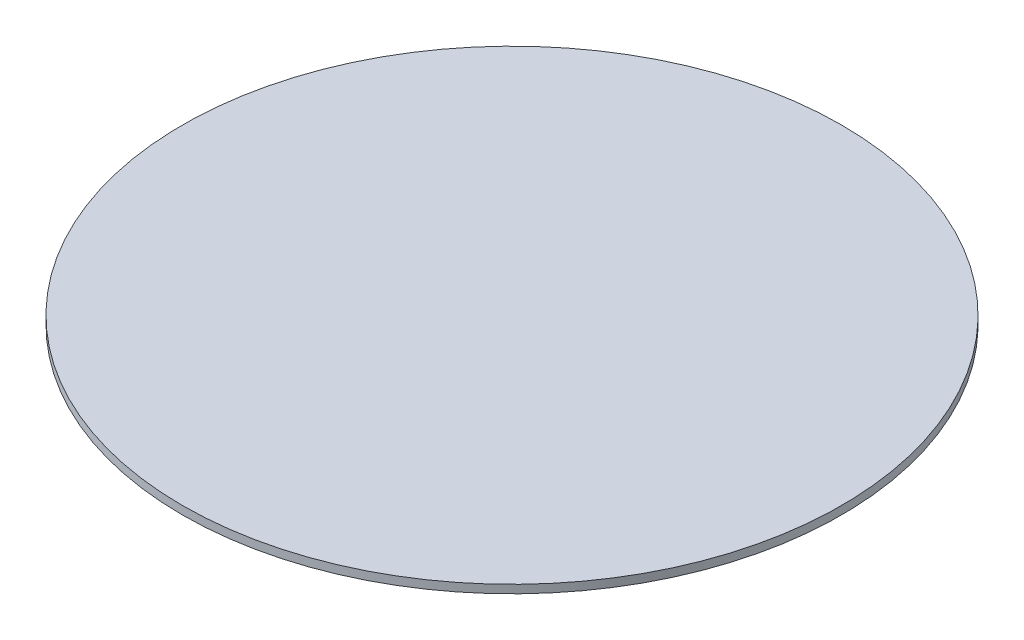
from build123d import *

# Parameters (mm, degrees)
SKETCH1_R           = 60
BOSS_EXTRUDE1_DEPTH = 1.5


with BuildPart() as part:
    # Sketch1 → Boss-Extrude1 (new body)
    with BuildSketch(Plane(origin=(0, 0, 0), x_dir=(1, 0, 0), z_dir=(0, 1, 0))):
        Circle(SKETCH1_R)
    extrude(amount=BOSS_EXTRUDE1_DEPTH)


solid = part.part
